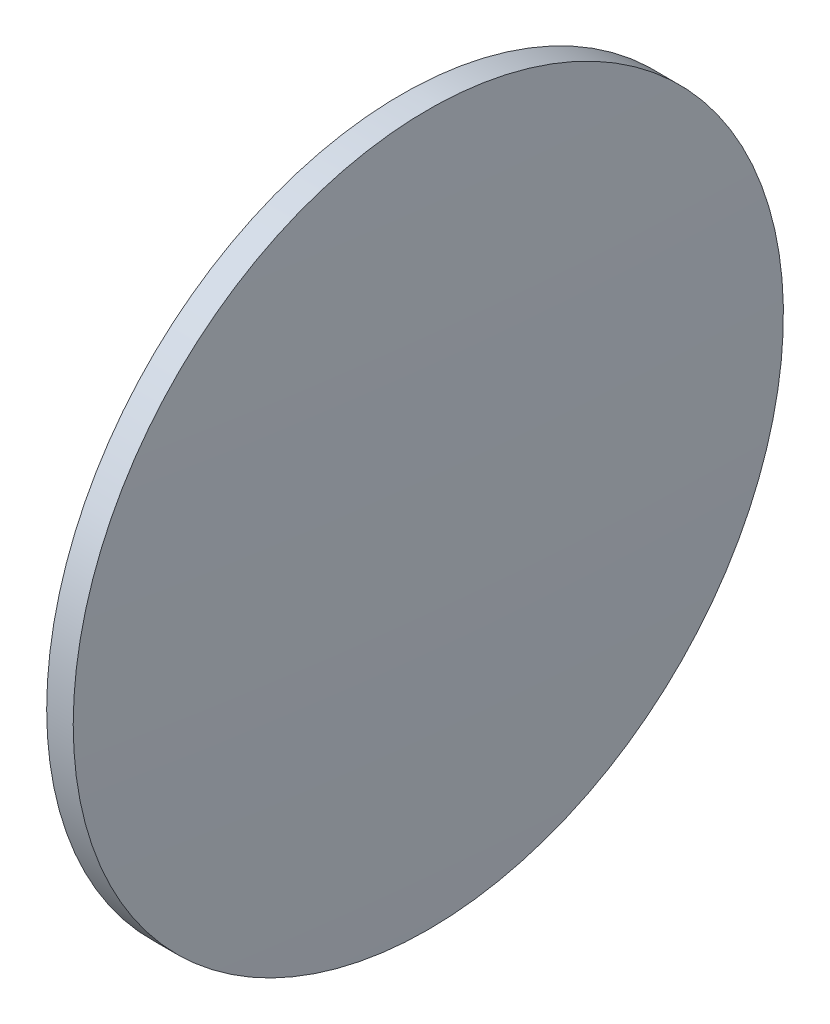
from build123d import *


with BuildPart() as part:
    # 草图1 → 旋转1 (revolve)
    with BuildSketch(Plane.XY, mode=Mode.PRIVATE) as revolve_1_sk:
        with BuildLine():
            Line((236.156126338, 130.04189076), (236.156126338, 170.04189076))
            Line((236.156126338, 170.04189076), (239.146126338, 170.04189076))
            ThreePointArc((239.146126338, 170.04189076), (239.723608508, 150.045596042), (239.916126338, 130.04189076))
            Line((239.916126338, 130.04189076), (236.156126338, 130.04189076))
        make_face()
    revolve(revolve_1_sk.sketch.rotate(Axis((217.331148661, 130.04189076, 0), (1, 0, 0)), 180), axis=Axis((217.331148661, 130.04189076, 0), (1, 0, 0)))  # turned: the seam where the file's is


solid = part.part
